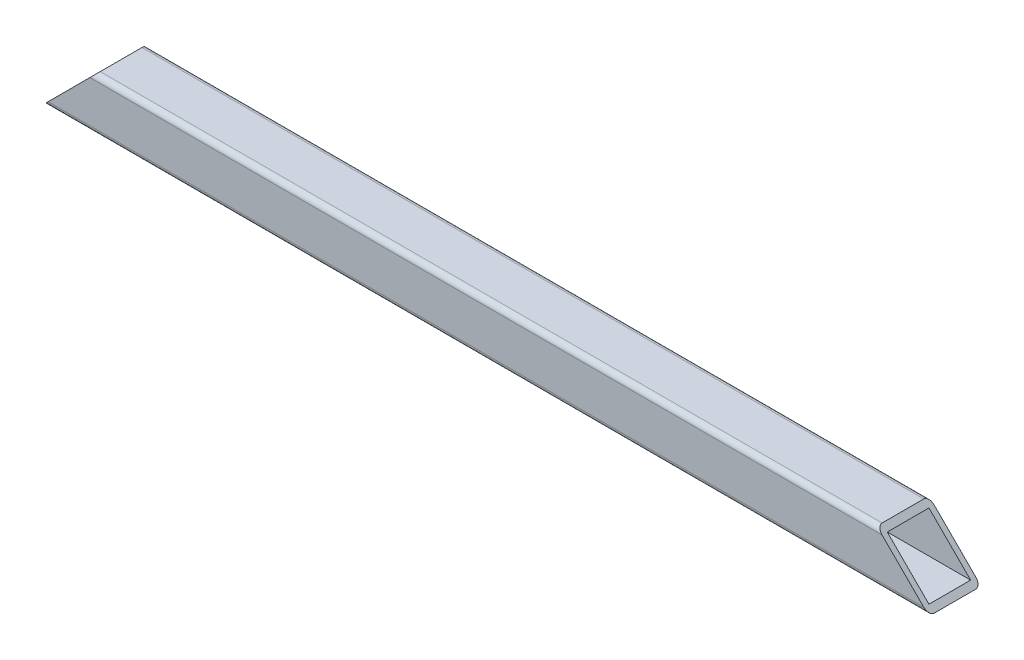
from build123d import *

# Parameters (mm, degrees)
SKETCH1_W           = 340.2
SKETCH1_H           = 20
BOSS_EXTRUDE1_DEPTH = 20
FILLET1_R           = 2
CUT_EXTRUDE1_DEPTH  = 21
SKETCH3_W           = 16
SKETCH3_H           = 16
CUT_EXTRUDE2_DEPTH  = 611.1


with BuildPart() as part:
    # Sketch1 → Boss-Extrude1 (new body)
    with BuildSketch(Plane.XY):
        with Locations((-440, -1090)):
            Rectangle(SKETCH1_W, SKETCH1_H)
    extrude(amount=-BOSS_EXTRUDE1_DEPTH)

    # Fillet1
    fillet1_edges = [part.edges().sort_by_distance(p)[0] for p in [
        (-440, -1100, -20),
        (-440, -1100, 0),
        (-440, -1080, 0),
        (-440, -1080, -20),
    ]]
    fillet(fillet1_edges, radius=FILLET1_R)

    # Sketch2 → Cut-Extrude1 (cut, through all)
    with BuildSketch(Plane.XY):
        Polygon((-269.9, -1100), (-269.9, -1080), (-289.9, -1080), align=None)
        Polygon((-610.1, -1100), (-590.1, -1080), (-610.1, -1080), align=None)
    extrude(amount=-CUT_EXTRUDE1_DEPTH, mode=Mode.SUBTRACT)

    # Sketch3 → Cut-Extrude2 (cut, through all)
    with BuildSketch(Plane(origin=(0, 0, 0), x_dir=(0, 0, -1), z_dir=(1, 0, 0))):
        with Locations((10, -1090)):
            Rectangle(SKETCH3_W, SKETCH3_H)
    extrude(amount=-CUT_EXTRUDE2_DEPTH, mode=Mode.SUBTRACT)


solid = part.part
